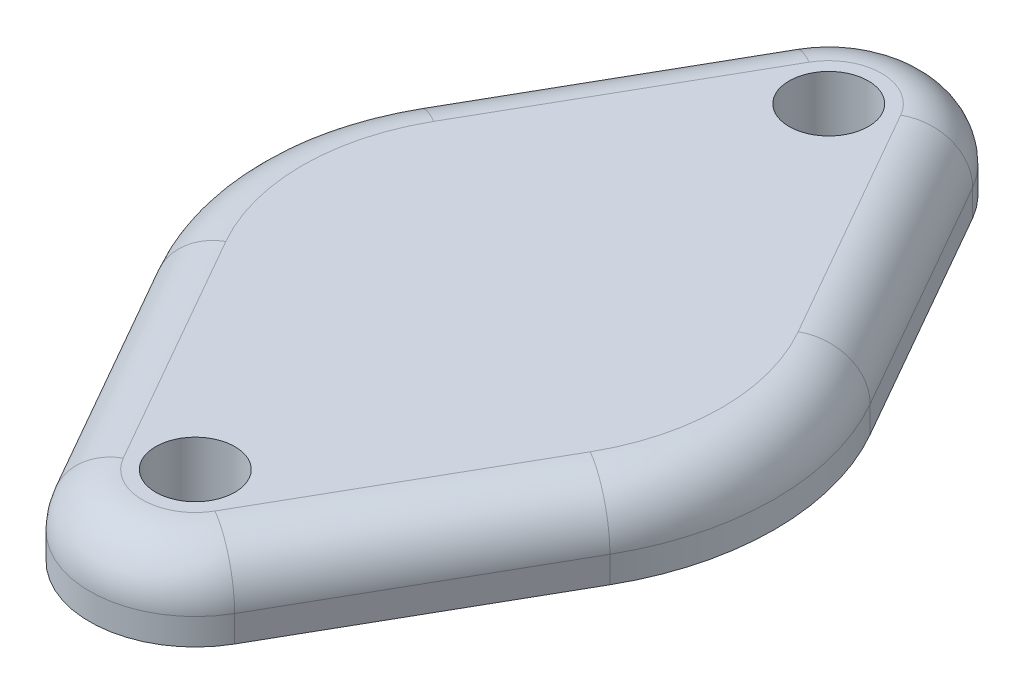
from build123d import *

# Parameters (mm, degrees)
SKETCH_1_R      = 1.5
EXTRUDE_1_DEPTH = 3
FILLET_1_R      = 2


with BuildPart() as part:
    # Эскиз1 → Бобышка-Вытянуть1 (new body)
    with BuildSketch(Plane(origin=(0, 0, 0), x_dir=(1, 0, 0), z_dir=(0, 1, 0))):
        with BuildLine():
            Line((-3.863363367, 13.30042486), (-8.639745084, 4.930152864))
            ThreePointArc((-8.639745084, 4.930152864), (-9.947442002, 0), (-8.639745084, -4.930152864))
            Line((-8.639745084, -4.930152864), (-3.47415751, -13.982480667))
            ThreePointArc((-3.47415751, -13.982480667), (0, -16), (3.47415751, -13.982480667))
            Line((3.47415751, -13.982480667), (8.639745084, -4.930152864))
            ThreePointArc((8.639745084, -4.930152864), (9.947442002, 0), (8.639745084, 4.930152864))
            Line((8.639745084, 4.930152864), (3.863363367, 13.30042486))
            Line((3.863363367, 13.30042486), (3.47415751, 13.982480667))
            ThreePointArc((3.47415751, 13.982480667), (0, 16), (-3.47415751, 13.982480667))
            Line((-3.47415751, 13.982480667), (-3.863363367, 13.30042486))
        make_face()
        with Locations((0, 12)):
            Circle(SKETCH_1_R, mode=Mode.SUBTRACT)
        with Locations((0, -12)):
            Circle(SKETCH_1_R, mode=Mode.SUBTRACT)
    extrude(amount=EXTRUDE_1_DEPTH)

    # Скругление1
    fillet_1_edges = [part.edges().sort_by_distance(p)[0] for p in [
        (0, 3, 16),
        (6.056951297, 3, 9.456316766),
        (9.947442002, 3, 0),
        (6.056951297, 3, -9.456316766),
        (0, 3, -16),
        (-6.056951297, 3, -9.456316766),
        (-9.947442002, 3, 0),
        (-6.056951297, 3, 9.456316766),
    ]]
    fillet(fillet_1_edges, radius=FILLET_1_R)


solid = part.part
